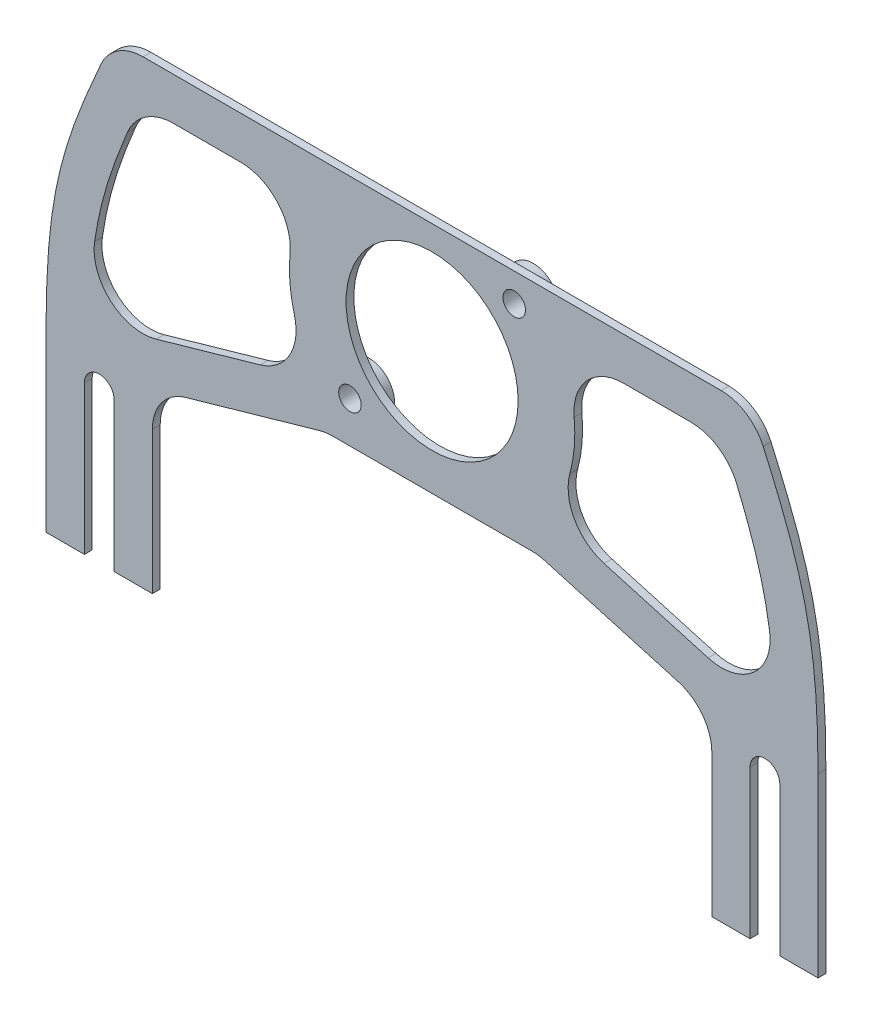
from build123d import *

# Parameters (mm, degrees)
SKETCH2_R            = 15.4305
SKETCH2_R_2          = 2.0193
BOSS_EXTRUDE1_DEPTH  = 1.4
FILLET4_R            = 8.255
CUT_EXTRUDE1_DEPTH   = 2.4000001
FILLET5_R            = 8.89
FILLET5_OF_MIRROR1_R = 8.89
SKETCH8_R            = 4.5593
SKETCH8_R_2          = 2.0193
BOSS_EXTRUDE2_DEPTH  = 2.029


with BuildPart() as part:
    # Sketch2 → Boss-Extrude1 (new body)
    with BuildSketch(Plane.XY):
        with BuildLine():
            Line((-69.215, 12.7), (-69.215, 0))
            Line((-69.215, 0), (-62.357, 0))
            Line((-62.357, 0), (-62.357, 26.67))
            ThreePointArc((-62.357, 26.67), (-59.69, 29.337), (-57.023, 26.67))
            Line((-57.023, 26.67), (-57.023, 0))
            Line((-57.023, 0), (-50.165, 0))
            Line((-50.165, 0), (-50.165, 31.75))
            Line((-50.165, 31.75), (-19.05, 40.64))
            Line((-19.05, 40.64), (0, 40.64))
            Line((0, 40.64), (19.05, 40.64))
            Line((19.05, 40.64), (50.165, 31.75))
            Line((50.165, 31.75), (50.165, 0))
            Line((50.165, 0), (57.023, 0))
            Line((57.023, 0), (57.023, 26.67))
            ThreePointArc((57.023, 26.67), (59.69, 29.337), (62.357, 26.67))
            Line((62.357, 26.67), (62.357, 0))
            Line((62.357, 0), (69.215, 0))
            Line((69.215, 0), (69.215, 12.7))
            Line((69.215, 12.7), (69.215, 31.75))
            add(Edge.make_bspline(
                [(69.215, 31.75), (69.215, 54.201663529), (66.080158446, 63.077253183), (57.15, 82.55)],
                knots=[0, 0, 0, 0, 1, 1, 1, 1], degree=3))
            Line((57.15, 82.55), (-57.15, 82.55))
            add(Edge.make_bspline(
                [(-69.215, 31.75), (-69.215, 54.201663529), (-66.080158446, 63.077253183), (-57.15, 82.55)],
                knots=[0, 0, 0, 0, 1, 1, 1, 1], degree=3))
            Line((-69.215, 31.75), (-69.215, 12.7))
        make_face()
        with Locations((0, 62.742379961)):
            Circle(SKETCH2_R, mode=Mode.SUBTRACT)
        with Locations((-14.727620039, 48.014759923)):
            Circle(SKETCH2_R_2, mode=Mode.SUBTRACT)
        with Locations((14.727620039, 77.47)):
            Circle(SKETCH2_R_2, mode=Mode.SUBTRACT)
    extrude(amount=BOSS_EXTRUDE1_DEPTH)

    # Fillet4
    fillet4_edges = [part.edges().sort_by_distance(p)[0] for p in [
        (57.15, 82.55, 0.7),
        (-57.15, 82.55, 0.7),
        (50.165, 31.75, 0.7),
        (19.05, 40.64, 0.7),
        (-19.05, 40.64, 0.7),
        (-50.165, 31.75, 0.7),
    ]]
    fillet(fillet4_edges, radius=FILLET4_R)

    # Sketch7 → Cut-Extrude1 (cut, through all)
    with BuildSketch(Plane.XY.offset(1.4)):
        with BuildLine():
            Line((-22.501902321, 74.93), (-51.827314967, 74.93))
            Line((-51.827314967, 74.93), (-52.239495321, 74.93))
            Line((-52.239495321, 74.93), (-52.407305567, 74.553526409))
            add(Edge.make_bspline(
                [(-52.407305567, 74.553526409), (-53.292419845, 72.567818402), (-54.098016837, 70.709360728), (-55.558646263, 67.181996285), (-56.213641355, 65.513276159), (-57.386849267, 62.293765878), (-57.905181999, 60.743063744), (-58.823443884, 57.676179523), (-59.223597116, 56.159796082), (-59.922846669, 53.067471662), (-60.222031529, 51.491149103), (-60.491375272, 49.737636417), (-60.506543886, 49.637526891), (-60.521547991, 49.537125261)],
                knots=[0, 0, 0, 0, 0.125, 0.125, 0.25, 0.25, 0.375, 0.375, 0.5, 0.5, 0.625, 0.625, 0.632545784, 0.632545784, 0.632545784, 0.632545784], degree=3))
            ThreePointArc((-60.521547991, 49.537125261), (-57.650036676, 41.695346124), (-49.50226085, 39.864273665))
            Line((-49.50226085, 39.864273665), (-46.271197905, 40.787434507))
            Line((-46.271197905, 40.787434507), (-20.935753267, 48.026132975))
            ThreePointArc((-20.935753267, 48.026132975), (-25.547250262, 61.255203349), (-22.501902321, 74.93))
        make_face()
    cut_extrude1 = extrude(amount=-CUT_EXTRUDE1_DEPTH, mode=Mode.SUBTRACT)

    # Fillet5
    fillet5_edges = [part.edges().sort_by_distance(p)[0] for p in [
        (-22.501902321, 74.93, 0.7),
        (-52.239495321, 74.93, 0.7),
        (-20.935753267, 48.026132975, 0.7),
    ]]
    fillet(fillet5_edges, radius=FILLET5_R)

    # Mirror1: Cut-Extrude1 across plane
    add(cut_extrude1.mirror(Plane(origin=(0, 0, 0), x_dir=(0, 0, 1), z_dir=(1, 0, 0))), mode=Mode.SUBTRACT)

    # Fillet5 of Mirror1
    fillet5_of_mirror1_edges = [part.edges().sort_by_distance(p)[0] for p in [
        (22.501902321, 74.93, 0.7),
        (52.239495321, 74.93, 0.7),
        (20.935753267, 48.026132975, 0.7),
    ]]
    fillet(fillet5_of_mirror1_edges, radius=FILLET5_OF_MIRROR1_R)

    # Sketch8 → Boss-Extrude2 (add)
    with BuildSketch(Plane(origin=(0, 0, 0), x_dir=(-1, 0, 0), z_dir=(0, 0, -1))):
        with Locations((-14.727620039, 77.47)):
            Circle(SKETCH8_R)
        with Locations((-14.727620039, 77.47)):
            Circle(SKETCH8_R_2, mode=Mode.SUBTRACT)
        with Locations((14.727620039, 48.014759923)):
            Circle(SKETCH8_R)
        with Locations((14.727620039, 48.014759923)):
            Circle(SKETCH8_R_2, mode=Mode.SUBTRACT)
    extrude(amount=BOSS_EXTRUDE2_DEPTH)


solid = part.part
